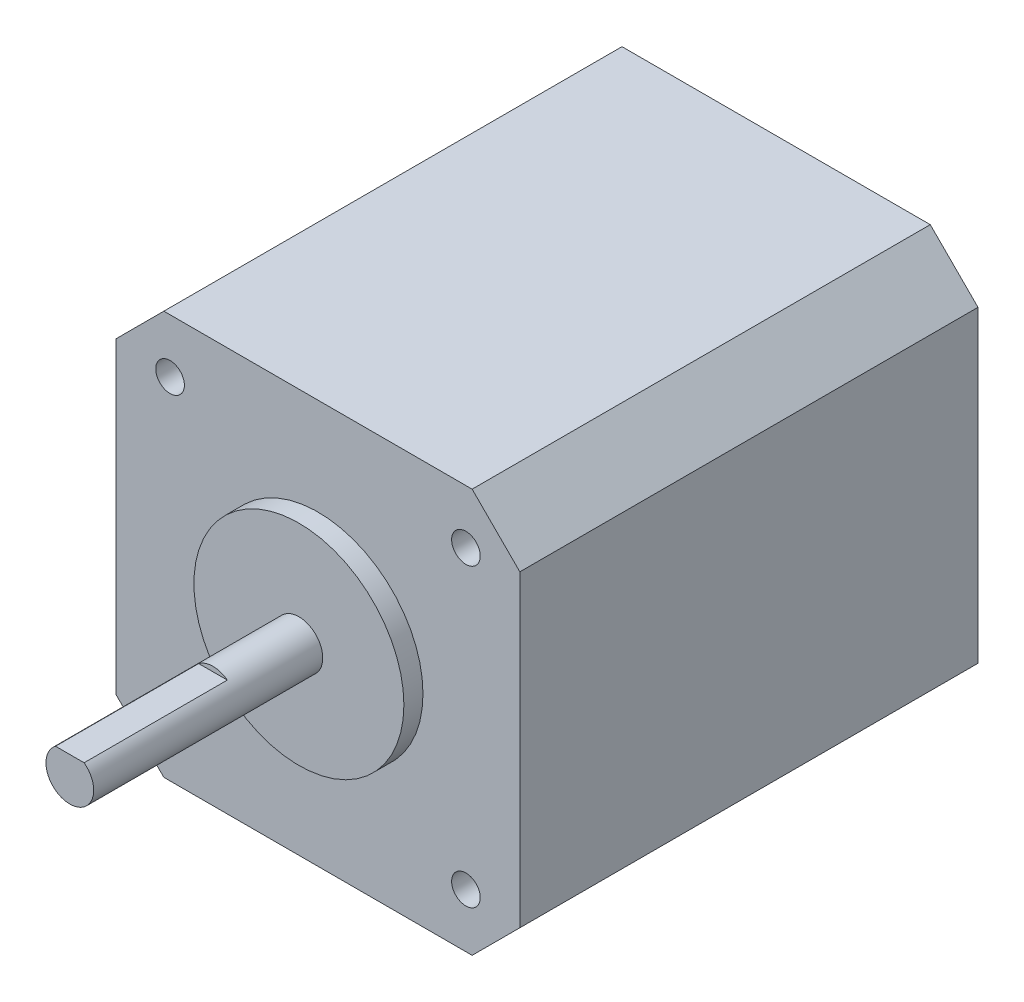
from build123d import *

# Parameters (mm, degrees)
SKETCH1_R           = 1.5
BOSS_EXTRUDE1_DEPTH = 48
SKETCH2_R           = 11
BOSS_EXTRUDE2_DEPTH = 2
SKETCH3_R           = 2.5
BOSS_EXTRUDE3_DEPTH = 24
CUT_EXTRUDE1_DEPTH  = 15
BOSS_EXTRUDE5_DEPTH = 13


with BuildPart() as part:
    # Sketch1 → Boss-Extrude1 (new body)
    with BuildSketch(Plane.XY):
        Polygon((0, 5), (0, 37.3), (5, 42.3), (37.3, 42.3), (42.3, 37.3), (42.3, 5), (37.3, 0), (5, 0), align=None)
        with Locations((5.65, 5.65)):
            Circle(SKETCH1_R, mode=Mode.SUBTRACT)
        with Locations((36.65, 5.65)):
            Circle(SKETCH1_R, mode=Mode.SUBTRACT)
        with Locations((36.65, 36.65)):
            Circle(SKETCH1_R, mode=Mode.SUBTRACT)
        with Locations((5.65, 36.65)):
            Circle(SKETCH1_R, mode=Mode.SUBTRACT)
    extrude(amount=BOSS_EXTRUDE1_DEPTH)

    # Sketch2 → Boss-Extrude2 (add)
    with BuildSketch(Plane.XY.offset(48)):
        with Locations((21.15, 21.15)):
            Circle(SKETCH2_R)
    extrude(amount=BOSS_EXTRUDE2_DEPTH)

    # Sketch3 → Boss-Extrude3 (add)
    with BuildSketch(Plane.XY.offset(50)):
        with Locations((21.15, 21.15)):
            Circle(SKETCH3_R)
    extrude(amount=BOSS_EXTRUDE3_DEPTH)

    # Sketch4 → Cut-Extrude1 (cut)
    with BuildSketch(Plane.XY.offset(74)):
        with BuildLine():
            Line((19.65, 23.15), (22.65, 23.15))
            ThreePointArc((22.65, 23.15), (21.15, 23.65), (19.65, 23.15))
        make_face()
    extrude(amount=-CUT_EXTRUDE1_DEPTH, mode=Mode.SUBTRACT)

    # Sketch5 → Boss-Extrude5 (add)
    with BuildSketch(Plane(origin=(0, 0, 0), x_dir=(-1, 0, 0), z_dir=(0, 0, -1))):
        with BuildLine():
            Line((-19.65, 23.15), (-22.65, 23.15))
            ThreePointArc((-22.65, 23.15), (-21.15, 18.65), (-19.65, 23.15))
        make_face()
    extrude(amount=BOSS_EXTRUDE5_DEPTH)


solid = part.part
